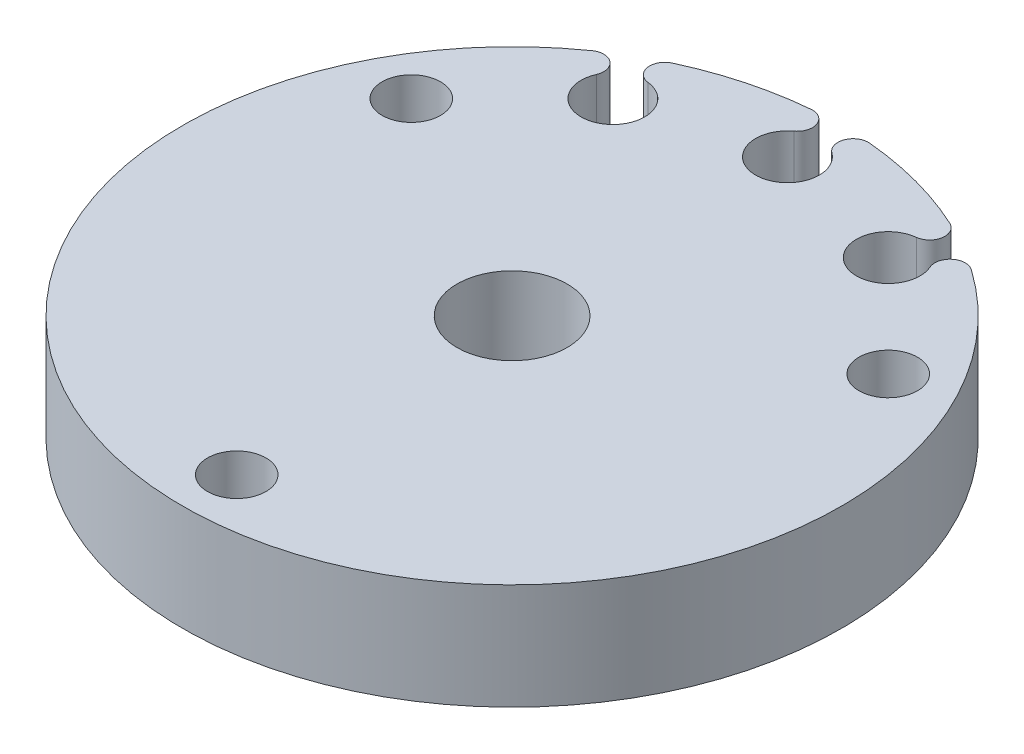
from build123d import *

# Parameters (mm, degrees)
SKETCH1_R           = 19.75
SKETCH1_R_2         = 3.302
SKETCH1_R_3         = 1.75
BOSS_EXTRUDE1_DEPTH = 6.35
CUT_EXTRUDE1_DEPTH  = 7.35
CIRPATTERN1_COUNT   = 3
CIRPATTERN1_ANGLE   = 60


with BuildPart() as part:
    # Sketch1 → Boss-Extrude1 (new body)
    with BuildSketch(Plane(origin=(0, 0, 0), x_dir=(1, 0, 0), z_dir=(0, 1, 0))):
        with Locations(Location((0, 0, 0), (0, 0, 270))):  # turned: the seam where the file's is
            Circle(SKETCH1_R)
        with Locations(Location((0, 0, 0), (0, 0, 270))):  # turned: the seam where the file's is
            Circle(SKETCH1_R_2, mode=Mode.SUBTRACT)
        with Locations(Location((-14.289419162, 8.25, 0), (0, 0, 270))):  # turned: the seam where the file's is
            Circle(SKETCH1_R_3, mode=Mode.SUBTRACT)
        with Locations(Location((0, -16.5, 0), (0, 0, 270))):  # turned: the seam where the file's is
            Circle(SKETCH1_R_3, mode=Mode.SUBTRACT)
        with Locations(Location((14.289419162, 8.25, 0), (0, 0, 270))):  # turned: the seam where the file's is
            Circle(SKETCH1_R_3, mode=Mode.SUBTRACT)
    extrude(amount=BOSS_EXTRUDE1_DEPTH)

    # Sketch2 → Cut-Extrude1 (cut, through all)
    with BuildSketch(Plane(origin=(0, 6.35, 0), x_dir=(1, 0, 0), z_dir=(0, 1, 0))):
        with BuildLine():
            ThreePointArc((8.036161973, 16.182379357), (7.2975, 12.639640768), (9.99627063, 15.050710096))
            ThreePointArc((9.99627063, 15.050710096), (10.255103275, 16.120005739), (11.354562521, 16.159715652))
            ThreePointArc((11.354562521, 16.159715652), (9.875, 17.104001725), (8.317443012, 17.913197418))
            ThreePointArc((8.317443012, 17.913197418), (8.832782842, 16.941182824), (8.036161973, 16.182379357))
        make_face()
    cut_extrude1 = extrude(amount=-CUT_EXTRUDE1_DEPTH, mode=Mode.SUBTRACT)

    # CirPattern1: Cut-Extrude1 ×3 about axis
    cirpattern1_axis = Axis((0, 0, 0), (0, 1, 0))
    for i in range(1, CIRPATTERN1_COUNT):
        add(cut_extrude1.rotate(cirpattern1_axis, i * CIRPATTERN1_ANGLE / (CIRPATTERN1_COUNT - 1)), mode=Mode.SUBTRACT)


solid = part.part
